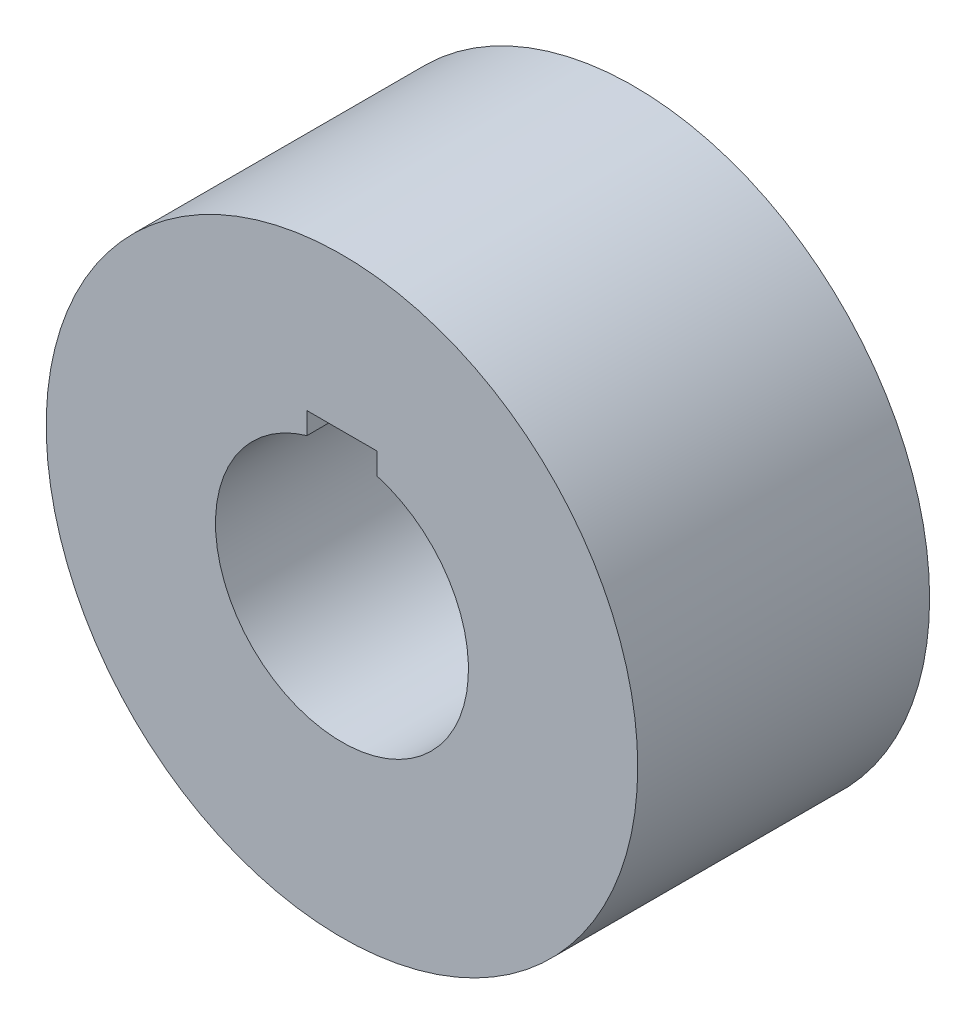
from build123d import *

# Parameters (mm, degrees)
SKETCH1_R           = 76
BOSS_EXTRUDE1_DEPTH = 75


with BuildPart() as part:
    # Sketch1 → Boss-Extrude1 (new body)
    with BuildSketch(Plane.XY):
        Circle(SKETCH1_R)
        with BuildLine():
            Line((-9, 31.228992939), (-9, 36.8))
            Line((-9, 36.8), (9, 36.8))
            Line((9, 36.8), (9, 31.228992939))
            ThreePointArc((9, 31.228992939), (0, -32.5), (-9, 31.228992939))
        make_face(mode=Mode.SUBTRACT)
    extrude(amount=BOSS_EXTRUDE1_DEPTH)


solid = part.part
